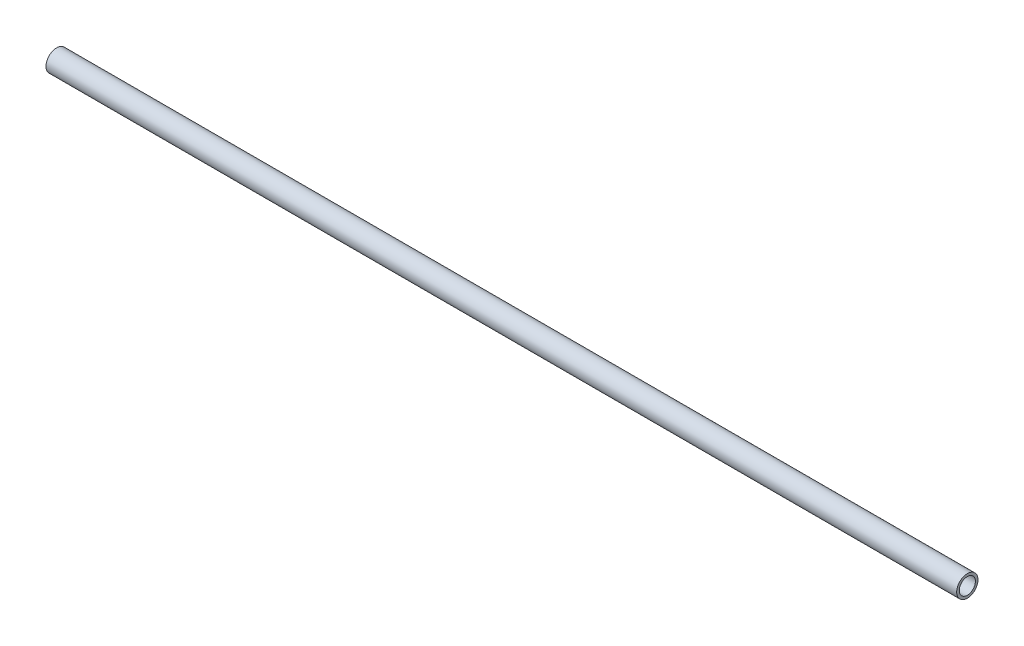
from build123d import *

# Parameters (mm, degrees)
SKETCH1_R           = 1.0541
SKETCH1_R_2         = 0.8001
BOSS_EXTRUDE1_DEPTH = 90
CUT_EXTRUDE2_DEPTH  = 10


with BuildPart() as part:
    # Sketch1 → Boss-Extrude1 (new body)
    with BuildSketch(Plane(origin=(0, 0, 0), x_dir=(0, 0, -1), z_dir=(1, 0, 0))):
        Circle(SKETCH1_R)
        Circle(SKETCH1_R_2, mode=Mode.SUBTRACT)
    extrude(amount=BOSS_EXTRUDE1_DEPTH)

    # Sketch3 → Cut-Extrude2 (cut)
    with BuildSketch(Plane.XY):
        with BuildLine():
            Line((1.079657865, 0.79375), (4.229657865, 0.79375))
            ThreePointArc((4.229657865, 0.79375), (5.023407865, 0), (4.229657865, -0.79375))
            Line((4.229657865, -0.79375), (1.079657865, -0.79375))
            ThreePointArc((1.079657865, -0.79375), (0.285907865, 0), (1.079657865, 0.79375))
        make_face()
    extrude(amount=-CUT_EXTRUDE2_DEPTH, mode=Mode.SUBTRACT)


solid = part.part
